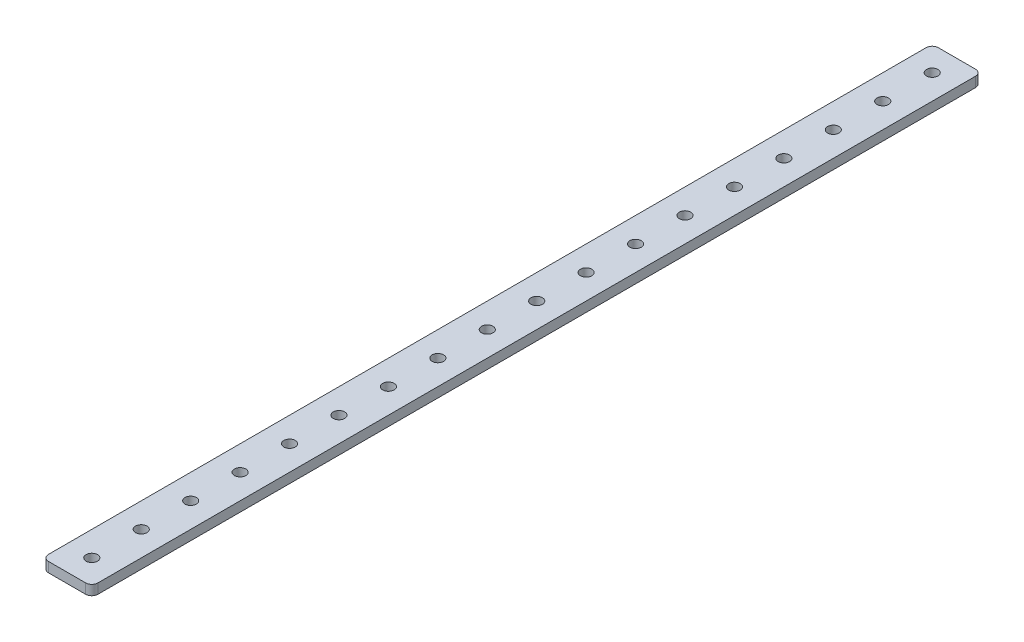
from build123d import *

# Parameters (mm, degrees)
SKETCH1_R           = 1.85
BOSS_EXTRUDE1_DEPTH = 3.2


with BuildPart() as part:
    # Sketch1 → Boss-Extrude1 (new body)
    with BuildSketch(Plane(origin=(0, 3.2, 0), x_dir=(1, 0, 0), z_dir=(0, 1, 0))):
        with BuildLine():
            Line((8, 2), (8, 286))
            ThreePointArc((8, 286), (7.414213562, 287.414213562), (6, 288))
            Line((6, 288), (-6, 288))
            ThreePointArc((-6, 288), (-7.414213562, 287.414213562), (-8, 286))
            Line((-8, 286), (-8, 2))
            ThreePointArc((-8, 2), (-7.414213562, 0.585786438), (-6, 0))
            Line((-6, 0), (6, 0))
            ThreePointArc((6, 0), (7.414213562, 0.585786438), (8, 2))
        make_face()
        with Locations((0, 280)):
            Circle(SKETCH1_R, mode=Mode.SUBTRACT)
        with Locations((0, 264)):
            Circle(SKETCH1_R, mode=Mode.SUBTRACT)
        with Locations((0, 248)):
            Circle(SKETCH1_R, mode=Mode.SUBTRACT)
        with Locations((0, 232)):
            Circle(SKETCH1_R, mode=Mode.SUBTRACT)
        with Locations((0, 216)):
            Circle(SKETCH1_R, mode=Mode.SUBTRACT)
        with Locations((0, 200)):
            Circle(SKETCH1_R, mode=Mode.SUBTRACT)
        with Locations((0, 184)):
            Circle(SKETCH1_R, mode=Mode.SUBTRACT)
        with Locations((0, 168)):
            Circle(SKETCH1_R, mode=Mode.SUBTRACT)
        with Locations((0, 152)):
            Circle(SKETCH1_R, mode=Mode.SUBTRACT)
        with Locations((0, 136)):
            Circle(SKETCH1_R, mode=Mode.SUBTRACT)
        with Locations((0, 120)):
            Circle(SKETCH1_R, mode=Mode.SUBTRACT)
        with Locations((0, 104)):
            Circle(SKETCH1_R, mode=Mode.SUBTRACT)
        with Locations((0, 88)):
            Circle(SKETCH1_R, mode=Mode.SUBTRACT)
        with Locations((0, 72)):
            Circle(SKETCH1_R, mode=Mode.SUBTRACT)
        with Locations((0, 56)):
            Circle(SKETCH1_R, mode=Mode.SUBTRACT)
        with Locations((0, 40)):
            Circle(SKETCH1_R, mode=Mode.SUBTRACT)
        with Locations((0, 24)):
            Circle(SKETCH1_R, mode=Mode.SUBTRACT)
        with Locations((0, 8)):
            Circle(SKETCH1_R, mode=Mode.SUBTRACT)
    extrude(amount=-BOSS_EXTRUDE1_DEPTH)


solid = part.part
